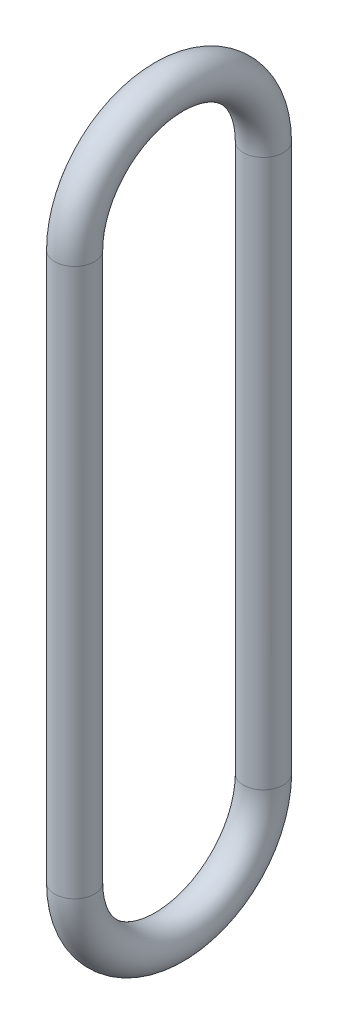
from build123d import *

# Parameters (mm, degrees)
SKETCH2_R = 6.35


with BuildPart() as part:
    # Sweep1: sweep along a path in Sketch3
    with BuildLine(Plane(origin=(0, 0, 0), x_dir=(0, 0, -1), z_dir=(1, 0, 0))) as sweep1_path:
        Line((0, 0), (0, 175.02378))
        ThreePointArc((0, 175.02378), (-30.1625, 205.18628), (-60.325, 175.02378))
        Line((-60.325, 175.02378), (-60.325, 0))
        ThreePointArc((-60.325, 0), (-30.1625, -30.1625), (0, 0))
    # Sketch2 → Sweep1 (sweep)
    with BuildSketch(Plane(origin=(0, 0, 0), x_dir=(1, 0, 0), z_dir=(0, 1, 0))):
        Circle(SKETCH2_R)
    sweep(path=sweep1_path.line)


solid = part.part
